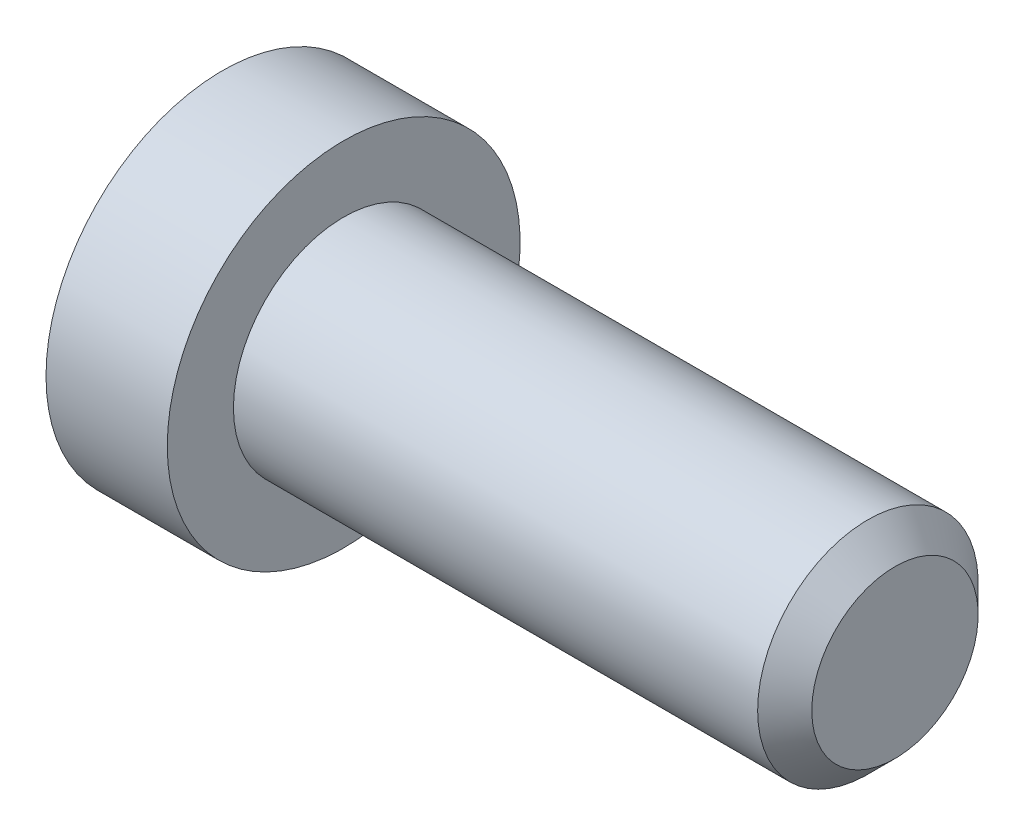
from build123d import *

# Parameters (mm, degrees)
SKETCH2_W          = 1.1
SKETCH2_H          = 1.6
CUT_EXTRUDE1_DEPTH = 1.2


with BuildPart() as part:
    # Sketch1 → Revolve1 (revolve)
    with BuildSketch(Plane.XY):
        Polygon((0, 0), (0, 1), (4.7545, 1), (5, 0.7545), (5, 0), align=None)
    revolve(axis=Axis((5, 0, 0), (-1, 0, 0)))

    # Sketch2 → Revolve2 (revolve)
    with BuildSketch(Plane.XY):
        with Locations((-0.55, 0.8)):
            Rectangle(SKETCH2_W, SKETCH2_H)
    revolve(axis=Axis((0, 0, 0), (-1, 0, 0)))

    # Sketch3 → Cut-Revolve1 (revolve, cut)
    with BuildSketch(Plane.XY):
        Polygon((-1.1, 0), (-1.1, 0.78), (-0.97, 0.65), (0.1, 0.65), (0.475277675, 0), align=None)
    revolve(axis=Axis((0.475277675, 0, 0), (-1, 0, 0)), mode=Mode.SUBTRACT)

    # Sketch4 → Cut-Extrude1 (cut)
    with BuildSketch(Plane(origin=(-1.1, 0, 0), x_dir=(0, 0, -1), z_dir=(1, 0, 0))):
        Polygon((-0.65, -0.375277675), (0, -0.75055535), (0.65, -0.375277675), (0.65, 0.375277675), (0, 0.75055535), (-0.65, 0.375277675), align=None)
    extrude(amount=CUT_EXTRUDE1_DEPTH, mode=Mode.SUBTRACT)


solid = part.part
